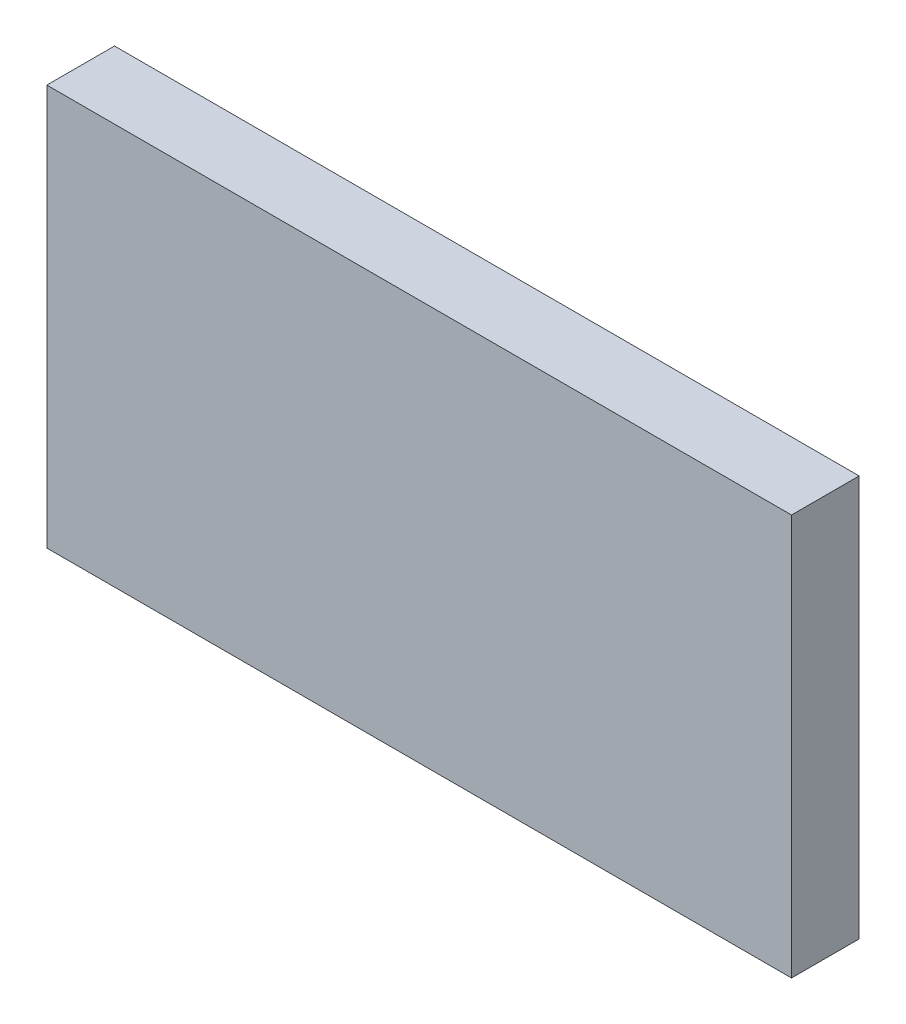
from build123d import *

# Parameters (mm, degrees)
SKETCH1_W           = 33.02
SKETCH1_H           = 17.78
BOSS_EXTRUDE1_DEPTH = 3


with BuildPart() as part:
    # Sketch1 → Boss-Extrude1 (new body)
    with BuildSketch(Plane.XY):
        with Locations((-16.51, 8.89)):
            Rectangle(SKETCH1_W, SKETCH1_H)
    extrude(amount=BOSS_EXTRUDE1_DEPTH)


solid = part.part
